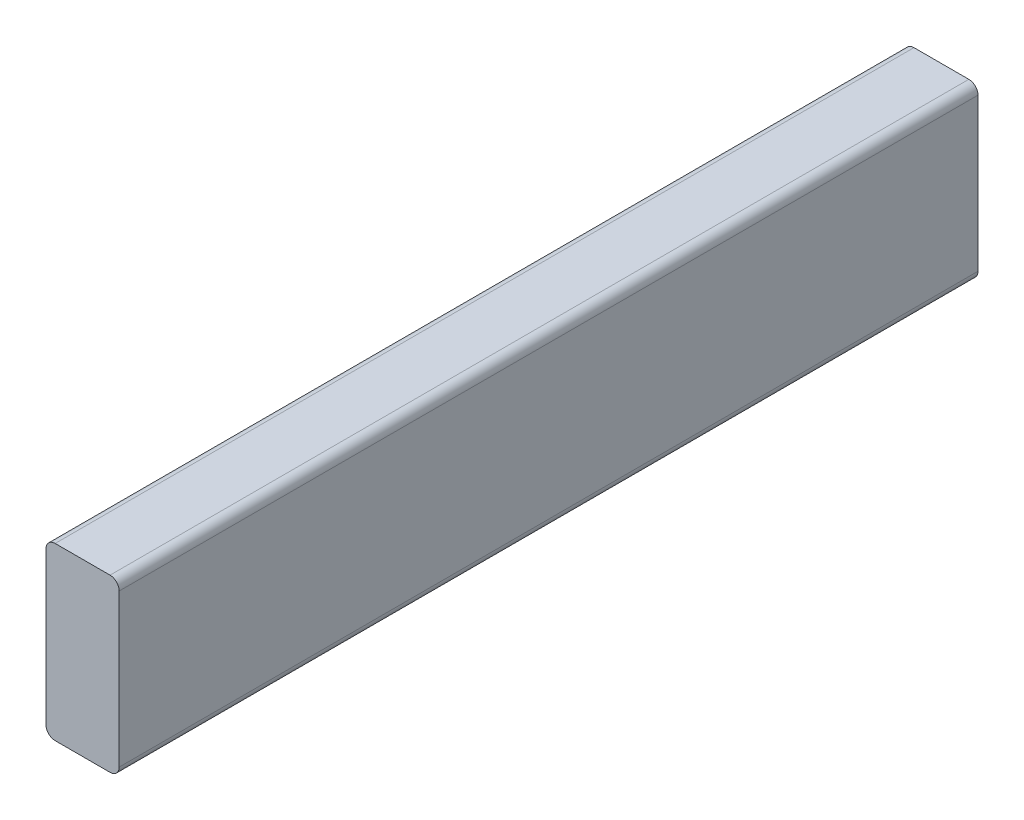
from build123d import *

# Parameters (mm, degrees)
SKETCH1_W           = 38.1
SKETCH1_H           = 88.9
BOSS_EXTRUDE1_DEPTH = 446.9765
FILLET1_R           = 4.7625


with BuildPart() as part:
    # Sketch1 → Boss-Extrude1 (new body)
    with BuildSketch(Plane.XY):
        with Locations((-185.882187925, 396.100363878)):
            Rectangle(SKETCH1_W, SKETCH1_H)
    extrude(amount=-BOSS_EXTRUDE1_DEPTH)

    # Fillet1
    fillet1_edges = [part.edges().sort_by_distance(p)[0] for p in [
        (-204.932187925, 351.650363878, -223.48825),
        (-166.832187925, 351.650363878, -223.48825),
        (-166.832187925, 440.550363878, -223.48825),
        (-204.932187925, 440.550363878, -223.48825),
    ]]
    fillet(fillet1_edges, radius=FILLET1_R)


solid = part.part
